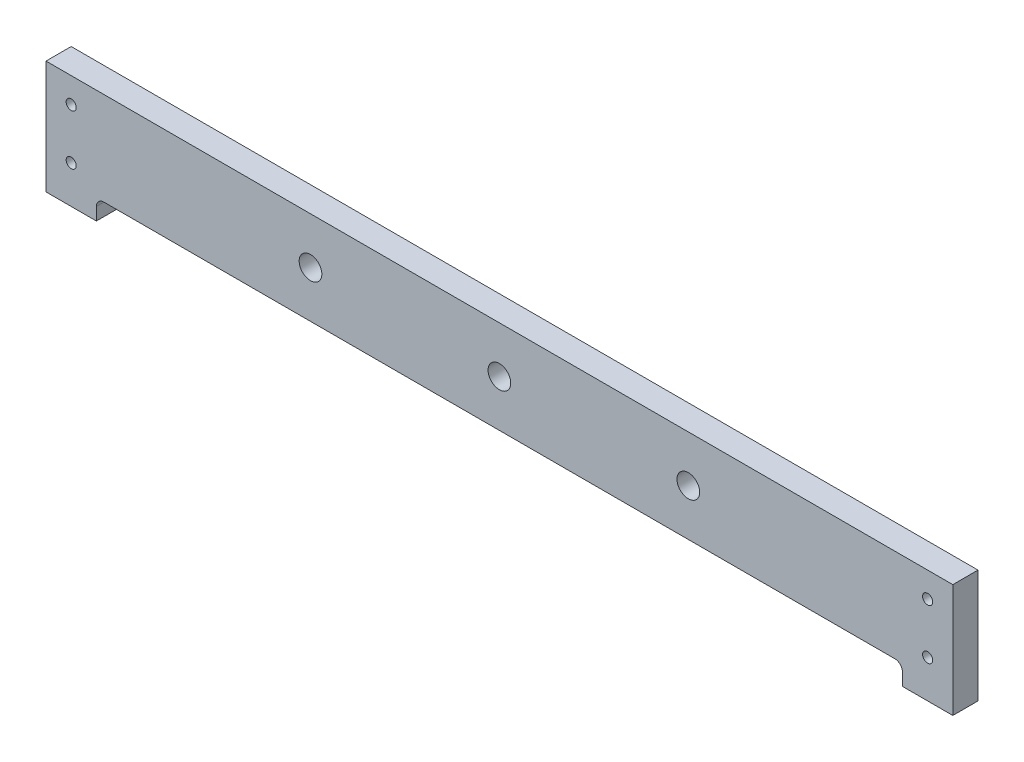
from build123d import *

# Parameters (mm, degrees)
SKETCH1_R           = 2
SKETCH1_R_2         = 4.5
BOSS_EXTRUDE1_DEPTH = 10


with BuildPart() as part:
    # Sketch1 → Boss-Extrude1 (new body)
    with BuildSketch(Plane.XY):
        with BuildLine():
            Line((0, 0), (360, 0))
            Line((360, 0), (360, -45))
            Line((360, -45), (340, -45))
            Line((340, -45), (340, -40))
            ThreePointArc((340, -40), (339.121320344, -37.878679656), (337, -37))
            Line((337, -37), (23, -37))
            ThreePointArc((23, -37), (20.878679656, -37.878679656), (20, -40))
            Line((20, -40), (20, -45))
            Line((20, -45), (0, -45))
            Line((0, -45), (0, 0))
        make_face()
        with Locations((350, -10)):
            Circle(SKETCH1_R, mode=Mode.SUBTRACT)
        with Locations((350, -30)):
            Circle(SKETCH1_R, mode=Mode.SUBTRACT)
        with Locations((10, -10)):
            Circle(SKETCH1_R, mode=Mode.SUBTRACT)
        with Locations((10, -30.004476127)):
            Circle(SKETCH1_R, mode=Mode.SUBTRACT)
        with Locations((180, -18.5)):
            Circle(SKETCH1_R_2, mode=Mode.SUBTRACT)
        with Locations((255, -18.5)):
            Circle(SKETCH1_R_2, mode=Mode.SUBTRACT)
        with Locations((105, -18.5)):
            Circle(SKETCH1_R_2, mode=Mode.SUBTRACT)
    extrude(amount=BOSS_EXTRUDE1_DEPTH)


solid = part.part
